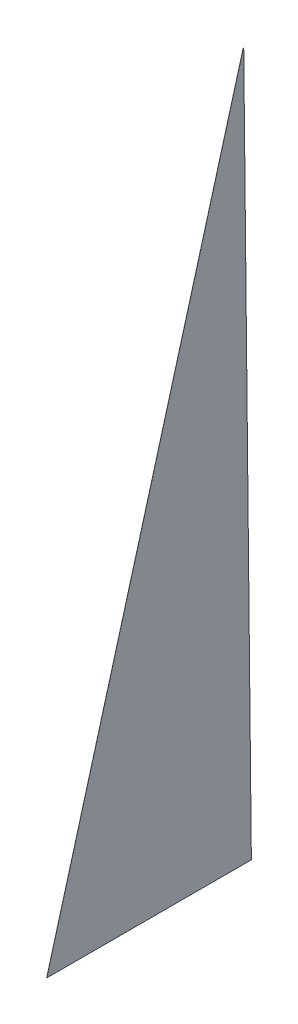
from build123d import *

# Parameters (mm, degrees)
BOSS_EXTRUDE1_DEPTH = 0.064008


with BuildPart() as part:
    # Sketch1 → Boss-Extrude1 (new body)
    with BuildSketch(Plane(origin=(0, 0, 0), x_dir=(0, 0, -1), z_dir=(1, 0, 0))):
        Polygon((0, 0), (168.45, 605.88), (175, 0), align=None)
    extrude(amount=BOSS_EXTRUDE1_DEPTH)


solid = part.part
